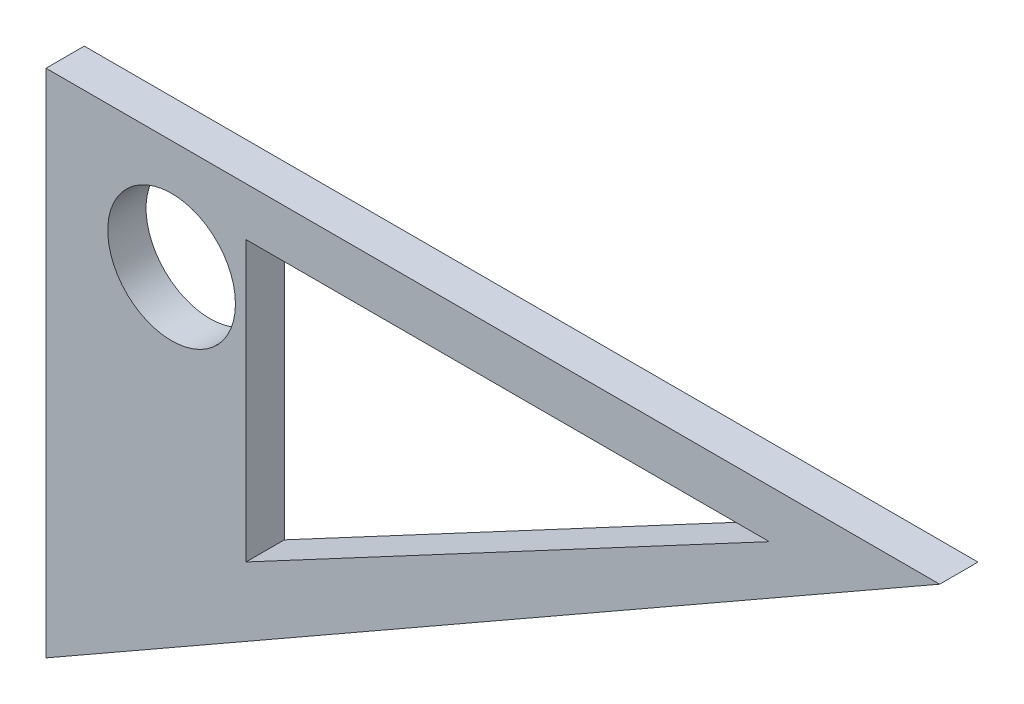
from build123d import *

# Parameters (mm, degrees)
SKETCH_1_R      = 5
EXTRUDE_1_DEPTH = 3


with BuildPart() as part:
    # 草图1 → 凸台-拉伸1 (new body)
    with BuildSketch(Plane.XY):
        Polygon((-9.837963803, 8.570517693), (60.162036197, 8.570517693), (-9.837963803, -31.429482307), align=None)
        Circle(SKETCH_1_R, mode=Mode.SUBTRACT)
        Polygon((5.831882272, 4.782203257), (5.831882272, -17.086702804), (46.814556623, 4.782203257), align=None, mode=Mode.SUBTRACT)
    extrude(amount=EXTRUDE_1_DEPTH)


solid = part.part
